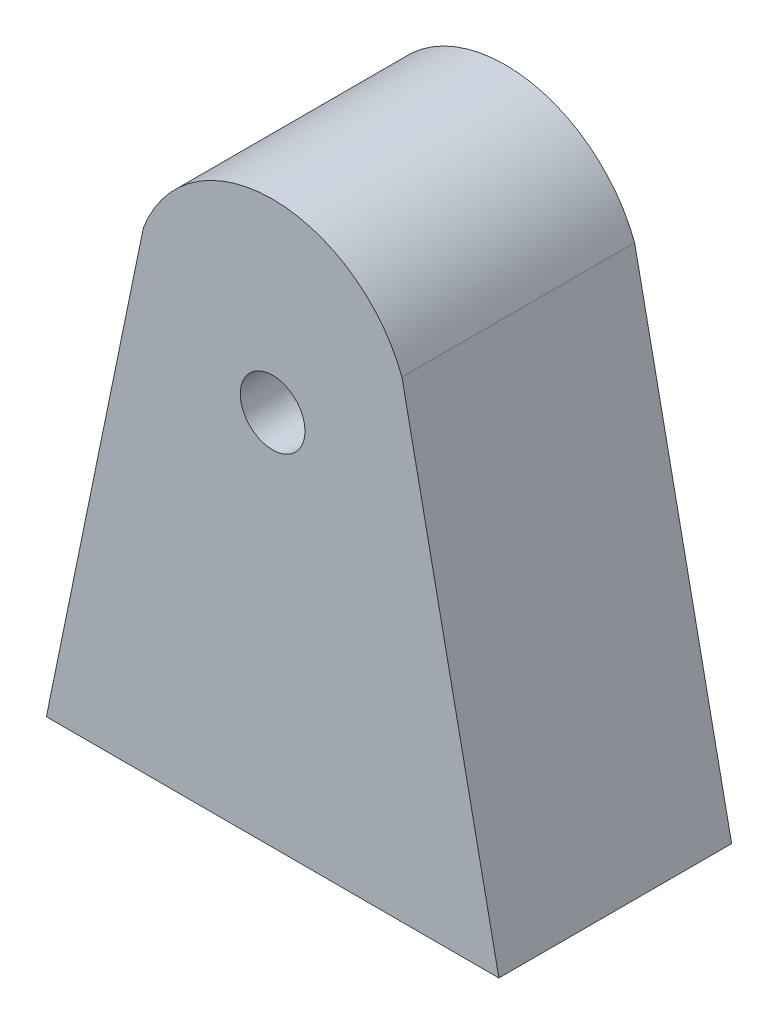
from build123d import *

# Parameters (mm, degrees)
BOSS_EXTRUDE1_DEPTH      = 45.72
SHELL1_T                 = -2.54
SHELL1_THICKNESS_2_DEPTH = 7.62
SHELL1_THICKNESS_3_DEPTH = 7.62
BOSS_EXTRUDE2_DEPTH      = 5.08
SKETCH3_R                = 6.35
CUT_EXTRUDE1_DEPTH       = 45.72
SKETCH4_W                = 5.08
SKETCH4_H                = 2.54
BOSS_EXTRUDE3_DEPTH      = 5.08
SKETCH5_W                = 2.54
SKETCH5_H                = 5.08
BOSS_EXTRUDE4_DEPTH      = 2.54
SKETCH6_W                = 5.08
SKETCH6_H                = 1.27
BOSS_EXTRUDE5_DEPTH      = 1.27


with BuildPart() as part:
    # Sketch1 → Boss-Extrude1 (new body)
    with BuildSketch(Plane.XY):
        with BuildLine():
            Line((0, 0), (-19.05, -92.71))
            Line((-19.05, -92.71), (69.85, -92.71))
            Line((69.85, -92.71), (50.8, 0))
            ThreePointArc((50.8, 0), (25.4, 17.565060875), (0, 0))
        make_face()
    extrude(amount=BOSS_EXTRUDE1_DEPTH)

    # Shell1
    shell1_openings = [part.faces().sort_by_distance(p)[0] for p in [
        (25.4, -92.71, 22.86),
    ]]
    offset(amount=SHELL1_T, openings=shell1_openings, kind=Kind.INTERSECTION)

    # Shell1 thickness 2 face (on inner face of the shell) → Shell1 thickness 2 (add)
    with BuildSketch(Plane(origin=(25.4, -46.578295761, 43.18), x_dir=(1, 0, 0), z_dir=(0, 0, 1))):
        with BuildLine():
            Line((41.856932666, -46.131704239), (-41.856932666, -46.131704239))
            Line((-41.856932666, -46.131704239), (-22.953477125, 45.865112726))
            ThreePointArc((-22.953477125, 45.865112726), (0, 61.603356636), (22.953477125, 45.865112726))
            Line((22.953477125, 45.865112726), (41.856932666, -46.131704239))
        make_face()
    extrude(amount=-SHELL1_THICKNESS_2_DEPTH)

    # Shell1 thickness 3 face (on inner face of the shell) → Shell1 thickness 3 (add)
    with BuildSketch(Plane(origin=(25.4, -46.578295761, 2.54), x_dir=(-1, 0, 0), z_dir=(0, 0, -1))):
        with BuildLine():
            Line((41.856932666, -46.131704239), (-41.856932666, -46.131704239))
            Line((-41.856932666, -46.131704239), (-22.953477125, 45.865112726))
            ThreePointArc((-22.953477125, 45.865112726), (0, 61.603356636), (22.953477125, 45.865112726))
            Line((22.953477125, 45.865112726), (41.856932666, -46.131704239))
        make_face()
    extrude(amount=-SHELL1_THICKNESS_3_DEPTH)

    # Sketch2 → Boss-Extrude2 (add)
    with BuildSketch(Plane(origin=(0, 0, 35.56), x_dir=(-1, 0, 0), z_dir=(0, 0, -1))):
        with BuildLine():
            Line((-48.353477125, -0.713183035), (-67.256932666, -92.71))
            Line((-67.256932666, -92.71), (16.456932666, -92.71))
            Line((16.456932666, -92.71), (-2.446522875, -0.713183035))
            ThreePointArc((-2.446522875, -0.713183035), (-11.484590973, 10.712623327), (-25.4, 15.025060875))
            ThreePointArc((-25.4, 15.025060875), (-39.315409027, 10.712623327), (-48.353477125, -0.713183035))
        make_face()
    extrude(amount=BOSS_EXTRUDE2_DEPTH)

    # Sketch3 → Cut-Extrude1 (cut)
    with BuildSketch(Plane(origin=(0, 0, 0), x_dir=(-1, 0, 0), z_dir=(0, 0, -1))):
        with Locations((-25.4, -18.738085506)):
            Circle(SKETCH3_R)
    extrude(amount=-CUT_EXTRUDE1_DEPTH, mode=Mode.SUBTRACT)

    # Sketch4 → Boss-Extrude3 (add)
    with BuildSketch(Plane(origin=(2.488018693, -0.511236718, 0), x_dir=(0, 0, -1), z_dir=(0.979534919, -0.201274298, 0))):
        with Locations((-20.32, -45.602294641)):
            Rectangle(SKETCH4_W, SKETCH4_H)
    extrude(amount=BOSS_EXTRUDE3_DEPTH)

    # Sketch5 → Boss-Extrude4 (add)
    with BuildSketch(Plane(origin=(-8.922951498, -43.425030624, 0), x_dir=(0.979534919, -0.201274298, 0), z_dir=(0.201274298, 0.979534919, 0))):
        with Locations((6.35, -20.32)):
            Rectangle(SKETCH5_W, SKETCH5_H)
    extrude(amount=BOSS_EXTRUDE4_DEPTH)

    # Sketch6 → Boss-Extrude5 (add)
    with BuildSketch(Plane(origin=(4.976037387, -1.022473436, 0), x_dir=(0, 0, 1), z_dir=(-0.979534919, 0.201274298, 0))):
        with Locations((20.32, -42.427294641)):
            Rectangle(SKETCH6_W, SKETCH6_H)
    extrude(amount=BOSS_EXTRUDE5_DEPTH)


solid = part.part
